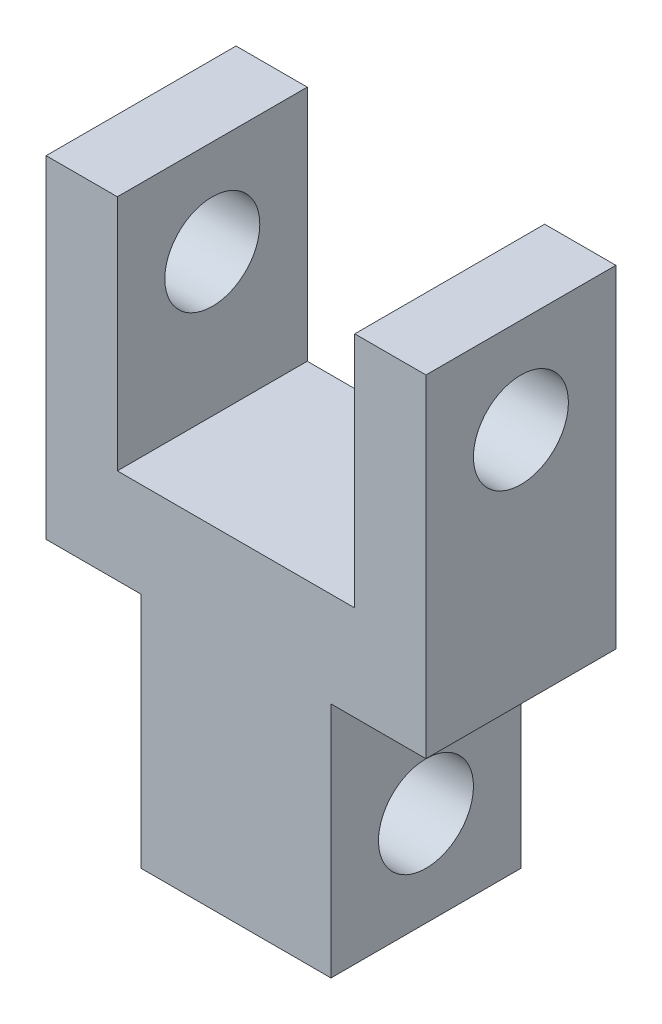
from build123d import *

# Parameters (mm, degrees)
BOSS_EXTRUDE1_DEPTH = 6.35
SKETCH2_R           = 3.175
CUT_EXTRUDE1_DEPTH  = 26.4
SKETCH3_R           = 3.175
CUT_EXTRUDE2_DEPTH  = 20.05


with BuildPart() as part:
    # Sketch1 → Boss-Extrude1 (new body, symmetric)
    with BuildSketch(Plane.XY):
        Polygon((-12.7, 38.1), (-12.7, 15.875), (-6.35, 15.875), (-6.35, 0), (6.35, 0), (6.35, 15.875), (12.7, 15.875), (12.7, 38.1), (7.9375, 38.1), (7.9375, 22.225), (-7.9375, 22.225), (-7.9375, 38.1), align=None)
    extrude(amount=BOSS_EXTRUDE1_DEPTH, both=True)

    # Sketch2 → Cut-Extrude1 (cut, through all)
    with BuildSketch(Plane(origin=(12.7, 0, 0), x_dir=(0, 0, -1), z_dir=(1, 0, 0))):
        with Locations((0, 31.75)):
            Circle(SKETCH2_R)
    extrude(amount=-CUT_EXTRUDE1_DEPTH, mode=Mode.SUBTRACT)

    # Sketch3 → Cut-Extrude2 (cut, through all)
    with BuildSketch(Plane(origin=(6.35, 0, 0), x_dir=(0, 0, -1), z_dir=(1, 0, 0))):
        with Locations((0, 6.35)):
            Circle(SKETCH3_R)
    extrude(amount=-CUT_EXTRUDE2_DEPTH, mode=Mode.SUBTRACT)


solid = part.part
